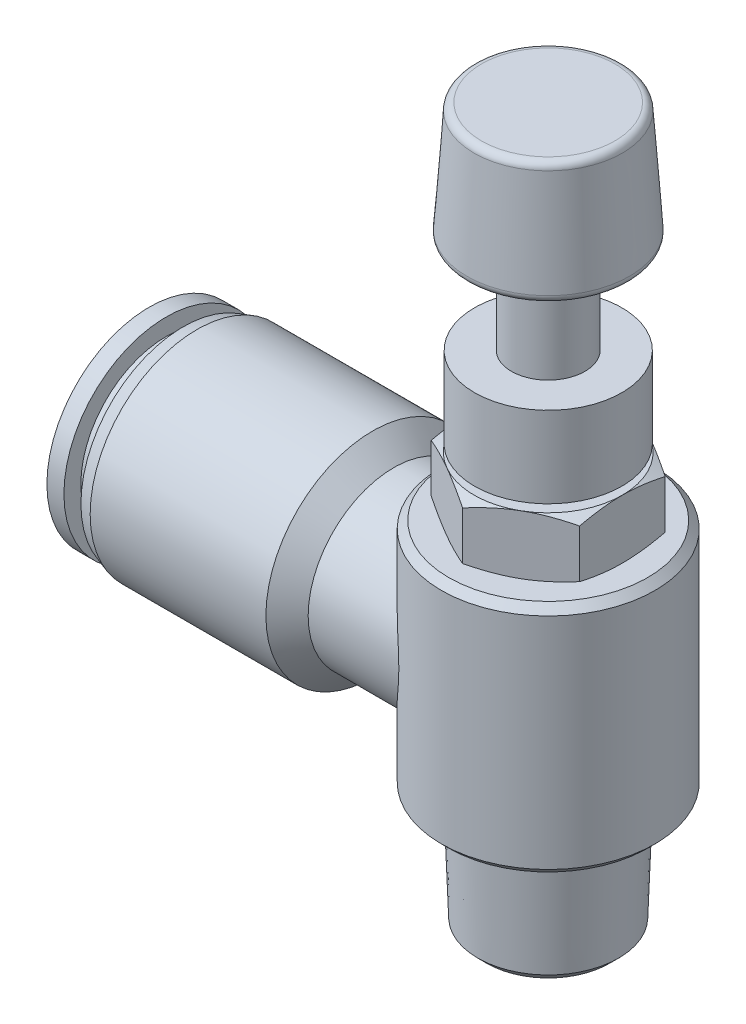
from build123d import *

# Parameters (mm, degrees)
CUT_EXTRUDE1_DEPTH = 3.96916


with BuildPart() as part:
    # Sketch1 → Revolve1 (revolve)
    with BuildSketch(Plane.XY):
        with BuildLine():
            Line((0, 32.3), (4.499259698, 32.3))
            ThreePointArc((4.499259698, 32.3), (4.840258878, 32.165676851), (4.998041723, 31.834878237))
            Line((4.998041723, 31.834878237), (5.483758073, 24.888810821))
            ThreePointArc((5.483758073, 24.888810821), (5.350652899, 24.512933404), (4.984976048, 24.353932584))
            Line((4.984976048, 24.353932584), (2.4768, 24.353932584))
            Line((2.4768, 24.353932584), (2.4768, 17.832081348))
            Line((2.4768, 17.832081348), (4.965517241, 17.832081348))
            Line((4.965517241, 17.832081348), (4.965517241, 12.36916))
            Line((4.965517241, 12.36916), (4, 12.36916))
            Line((4, 12.36916), (4, 11.86916))
            Line((4, 11.86916), (5, 11.86916))
            Line((5, 11.86916), (6, 11.402852342))
            Line((6, 11.402852342), (6, 8.366307658))
            Line((6, 8.366307658), (5, 7.9))
            Line((5, 7.9), (6.7, 7.9))
            Line((6.7, 7.9), (7.2, 7.4))
            Line((7.2, 7.4), (7.2, -7.4))
            Line((7.2, -7.4), (6.7, -7.9))
            Line((6.7, -7.9), (5.004037223, -7.9))
            Line((5.004037223, -7.9), (4.745792083, -15.295173238))
            Line((4.745792083, -15.295173238), (4.140965321, -15.9))
            Line((4.140965321, -15.9), (0, -15.9))
            Line((0, -15.9), (0, 32.3))
        make_face()
    revolve(axis=Axis((0, -15.9, 0), (0, 1, 0)))

    # Sketch2 → Cut-Extrude1 (cut)
    with BuildSketch(Plane(origin=(0, 11.86916, 0), x_dir=(1, 0, 0), z_dir=(0, 1, 0))):
        Polygon((-6.5, -3.75277675), (0, -7.505553499), (6.5, -3.75277675), (6.5, 3.75277675), (0, 7.505553499), (-6.5, 3.75277675), align=None)
        Polygon((-5, -2.886751346), (0, -5.773502692), (5, -2.886751346), (5, 2.886751346), (0, 5.773502692), (-5, 2.886751346), align=None, mode=Mode.SUBTRACT)
    extrude(amount=-CUT_EXTRUDE1_DEPTH, mode=Mode.SUBTRACT)

    # Sketch3 → Revolve2 (revolve)
    with BuildSketch(Plane.XY):
        Polygon((-26.9, 4), (0, 4), (0, 5.7744), (-10.4104, 5.7744), (-11.836, 7.2), (-23.683115991, 7.2), (-24.606421053, 6.9), (-24.606421053, 5.76), (-25.753210526, 5.76), (-25.753210526, 6.9), (-26.9, 6.9), align=None)
    revolve(axis=Axis((0, 0, 0), (-1, 0, 0)))


solid = part.part
